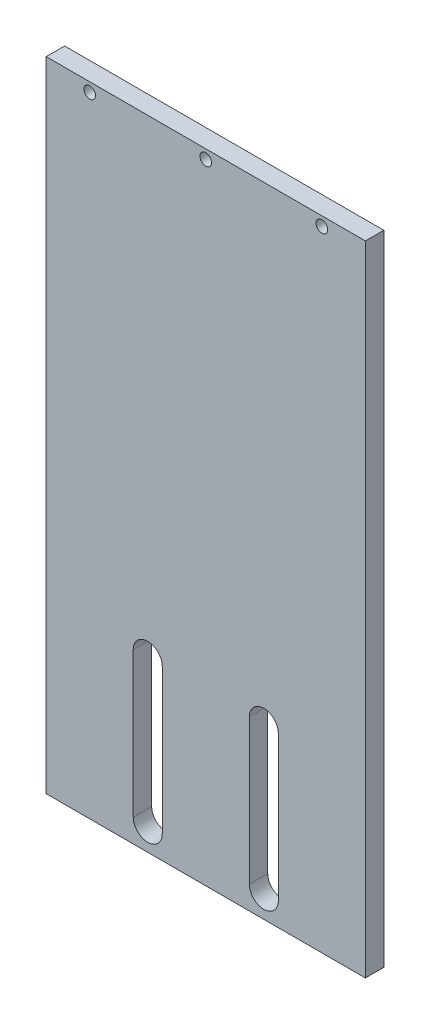
from build123d import *

# Parameters (mm, degrees)
CROQUIS1_W              = 110
CROQUIS1_H              = 220
SALIENTE_EXTRUIR1_DEPTH = 6.35
CROQUIS2_R              = 2
CORTAR_EXTRUIR2_DEPTH   = 7.35


with BuildPart() as part:
    # Croquis1 → Saliente-Extruir1 (new body)
    with BuildSketch(Plane.XY):
        Rectangle(CROQUIS1_W, CROQUIS1_H)
    extrude(amount=SALIENTE_EXTRUIR1_DEPTH)

    # Croquis2 → Cortar-Extruir2 (cut, through all)
    with BuildSketch(Plane.XY):
        with Locations((40, 106.825)):
            Circle(CROQUIS2_R)
        with Locations((-40, 106.825)):
            Circle(CROQUIS2_R)
        with Locations((0, 106.825)):
            Circle(CROQUIS2_R)
        with BuildLine():
            Line((-25, -52), (-25, -102))
            ThreePointArc((-25, -102), (-20, -107), (-15, -102))
            Line((-15, -102), (-15, -52))
            ThreePointArc((-15, -52), (-20, -47), (-25, -52))
        make_face()
        with BuildLine():
            Line((15, -52), (15, -102))
            ThreePointArc((15, -102), (20, -107), (25, -102))
            Line((25, -102), (25, -52))
            ThreePointArc((25, -52), (20, -47), (15, -52))
        make_face()
    extrude(amount=CORTAR_EXTRUIR2_DEPTH, mode=Mode.SUBTRACT)


solid = part.part
